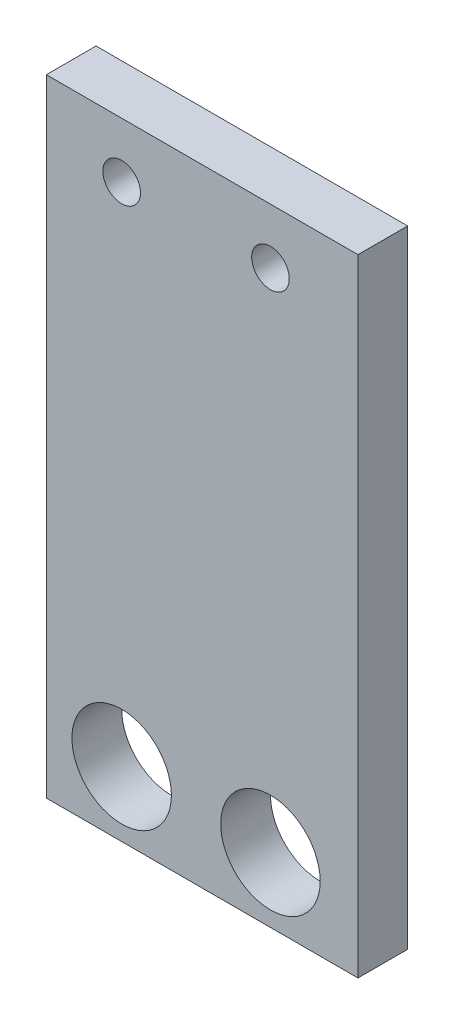
from build123d import *

# Parameters (mm, degrees)
SKETCH1_W           = 19.9
SKETCH1_H           = 40
SKETCH1_R           = 1.2
SKETCH1_R_2         = 3.175
BOSS_EXTRUDE1_DEPTH = 3.175


with BuildPart() as part:
    # Sketch1 → Boss-Extrude1 (new body)
    with BuildSketch(Plane.XY):
        with Locations((0.904028138, -4.296238371)):
            Rectangle(SKETCH1_W, SKETCH1_H)
        with Locations((-4.233971862, 12.17210412)):
            Circle(SKETCH1_R, mode=Mode.SUBTRACT)
        with Locations((5.266028138, 12.17210412)):
            Circle(SKETCH1_R, mode=Mode.SUBTRACT)
        with Locations((-4.233971862, -20.151760944)):
            Circle(SKETCH1_R_2, mode=Mode.SUBTRACT)
        with Locations((5.266028138, -20.151760944)):
            Circle(SKETCH1_R_2, mode=Mode.SUBTRACT)
    extrude(amount=BOSS_EXTRUDE1_DEPTH)


solid = part.part
